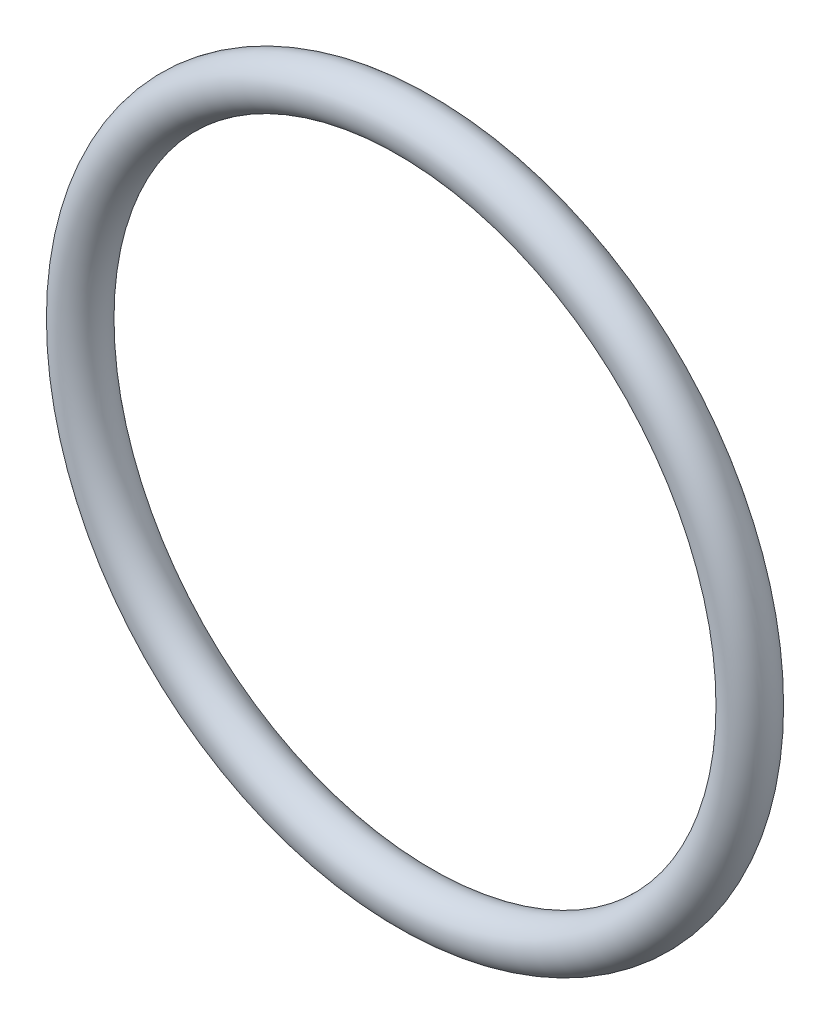
from build123d import *

# Parameters (mm, degrees)
SKETCH3_R = 0.5


with BuildPart() as part:
    # Sketch3 → Revolve1 (revolve)
    with BuildSketch(Plane(origin=(0, 0, 0), x_dir=(1, 0, 0), z_dir=(0, 1, 0))):
        with Locations((7, 0)):
            Circle(SKETCH3_R)
    revolve(axis=Axis((0, 0, 0.5), (0, 0, -1)))


solid = part.part
